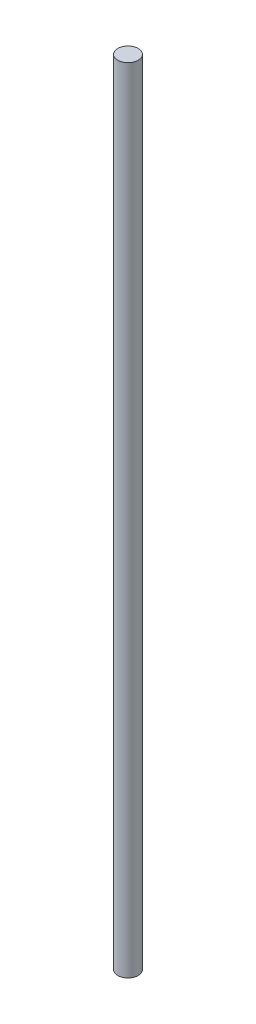
from build123d import *

# Parameters (mm, degrees)
SKETCH1_R           = 4
BOSS_EXTRUDE1_DEPTH = 310


with BuildPart() as part:
    # Sketch1 → Boss-Extrude1 (new body)
    with BuildSketch(Plane(origin=(0, 0, 0), x_dir=(1, 0, 0), z_dir=(0, 1, 0))):
        Circle(SKETCH1_R)
    extrude(amount=BOSS_EXTRUDE1_DEPTH)


solid = part.part
